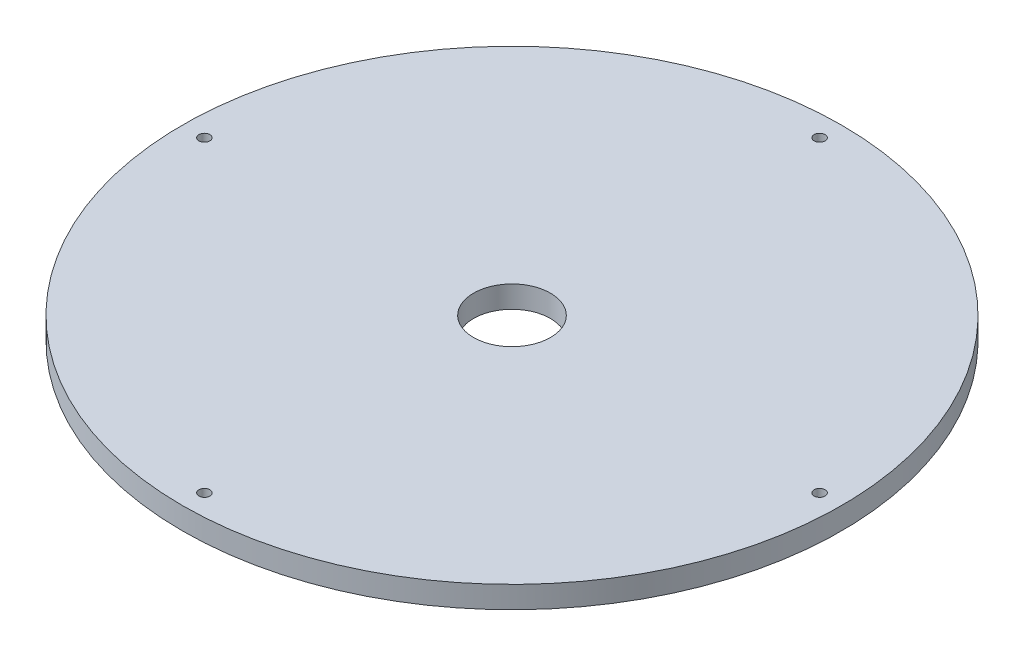
from build123d import *

# Parameters (mm, degrees)
SKETCH1_R           = 150
SKETCH1_R_2         = 17.5
SKETCH1_R_3         = 2.5
BOSS_EXTRUDE1_DEPTH = 10


with BuildPart() as part:
    # Sketch1 → Boss-Extrude1 (new body)
    with BuildSketch(Plane(origin=(0, 0, 0), x_dir=(1, 0, 0), z_dir=(0, 1, 0))):
        Circle(SKETCH1_R)
        Circle(SKETCH1_R_2, mode=Mode.SUBTRACT)
        with Locations((-140, 0)):
            Circle(SKETCH1_R_3, mode=Mode.SUBTRACT)
        with Locations((0, 140)):
            Circle(SKETCH1_R_3, mode=Mode.SUBTRACT)
        with Locations((140, 0)):
            Circle(SKETCH1_R_3, mode=Mode.SUBTRACT)
        with Locations((0, -140)):
            Circle(SKETCH1_R_3, mode=Mode.SUBTRACT)
    extrude(amount=BOSS_EXTRUDE1_DEPTH)


solid = part.part
